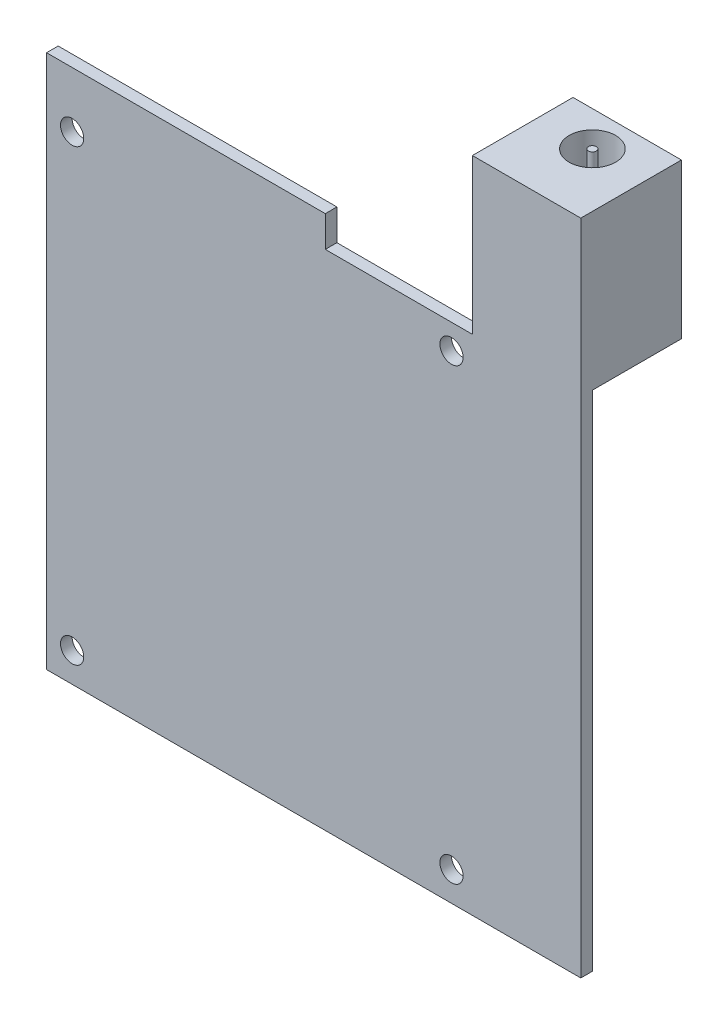
from build123d import *

# Parameters (mm, degrees)
SKETCH1_R           = 1.5
BOSS_EXTRUDE1_DEPTH = 1.5
SKETCH1_3_W         = 14
SKETCH1_3_H         = 20
BOSS_EXTRUDE2_DEPTH = 11.5
SKETCH2_R           = 3
SKETCH2_R_2         = 0.5
CUT_EXTRUDE1_DEPTH  = 10


with BuildPart() as part:
    # Sketch1 → Boss-Extrude1 (new body)
    with BuildSketch(Plane.XY):
        Polygon((55, 85), (55, 65), (36, 65), (36, 69), (0, 69), (0, 0), (69, 0), (69, 85), align=None)
        with Locations((52.3, 61.8)):
            Circle(SKETCH1_R, mode=Mode.SUBTRACT)
        with Locations((3.3, 3.8)):
            Circle(SKETCH1_R, mode=Mode.SUBTRACT)
        with Locations((52.3, 3.8)):
            Circle(SKETCH1_R, mode=Mode.SUBTRACT)
        with Locations((3.3, 61.8)):
            Circle(SKETCH1_R, mode=Mode.SUBTRACT)
    extrude(amount=BOSS_EXTRUDE1_DEPTH)

    # Sketch1_3 → Boss-Extrude2 (add)
    with BuildSketch(Plane.XY):
        with Locations((62, 75)):
            Rectangle(SKETCH1_3_W, SKETCH1_3_H)
    extrude(amount=-BOSS_EXTRUDE2_DEPTH)

    # Sketch2 → Cut-Extrude1 (cut)
    with BuildSketch(Plane(origin=(0, 85, 0), x_dir=(1, 0, 0), z_dir=(0, 1, 0))):
        with Locations(Location((62, 7, 0), (0, 0, 270))):  # turned: the seam where the file's is
            Circle(SKETCH2_R)
        with Locations(Location((62, 7, 0), (0, 0, 270))):  # turned: the seam where the file's is
            Circle(SKETCH2_R_2, mode=Mode.SUBTRACT)
    extrude(amount=-CUT_EXTRUDE1_DEPTH, mode=Mode.SUBTRACT)


solid = part.part
